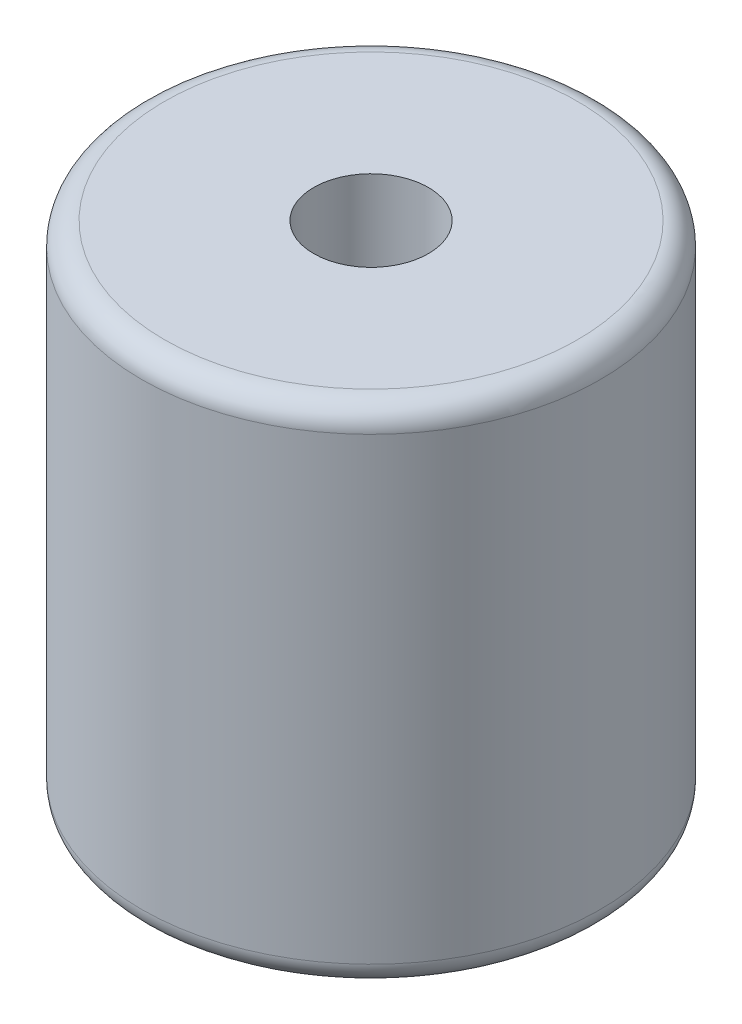
from build123d import *


with BuildPart() as part:
    # Sketch1 → Revolve1 (revolve)
    with BuildSketch(Plane(origin=(0, 0, 0), x_dir=(-1, 0, 0), z_dir=(0, 0, -1))):
        with BuildLine():
            Line((-6, -21), (-6, -5))
            Line((-6, -5), (-2.5, -5))
            Line((-2.5, -5), (-2.5, 0))
            Line((-2.5, 0), (-9, 0))
            ThreePointArc((-9, 0), (-9.707106781, -0.292893219), (-10, -1))
            Line((-10, -1), (-10, -21))
            ThreePointArc((-10, -21), (-9.707106781, -21.707106781), (-9, -22))
            Line((-9, -22), (-7, -22))
            ThreePointArc((-7, -22), (-6.292893219, -21.707106781), (-6, -21))
        make_face()
    revolve(axis=Axis((0, -22, 0), (0, 1, 0)))


solid = part.part
